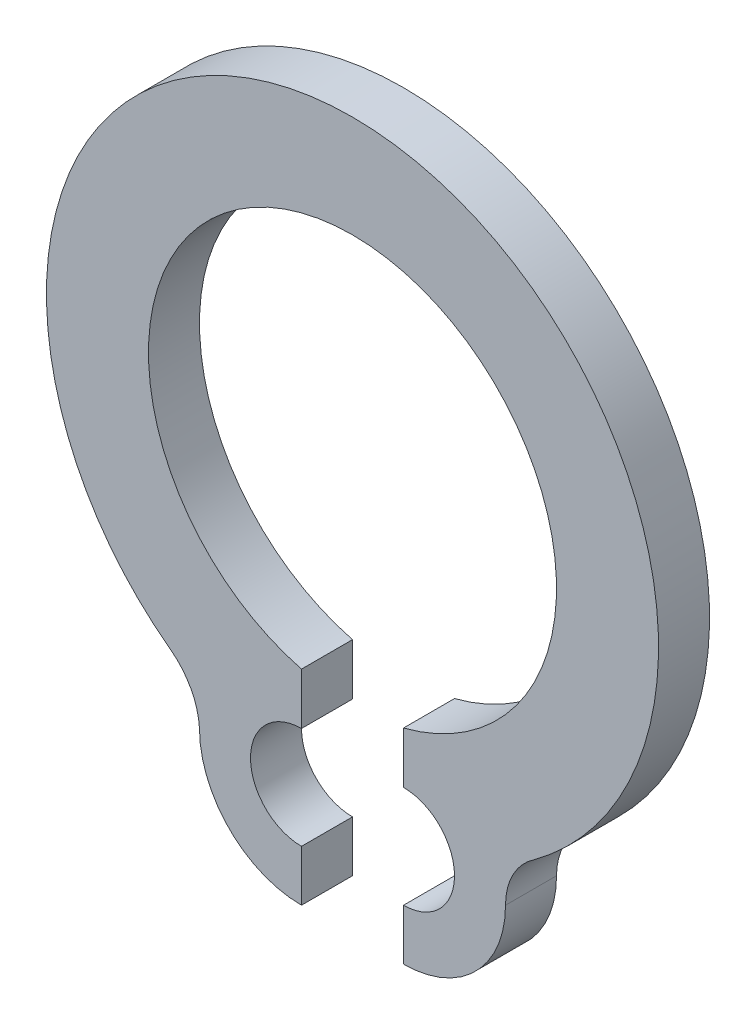
from build123d import *

# Parameters (mm, degrees)
SALIENTE_EXTRUIR1_DEPTH = 0.5


with BuildPart() as part:
    # Croquis1 → Saliente-Extruir1 (new body)
    with BuildSketch(Plane.XY):
        with BuildLine():
            Line((0.499989722, -2.441025539), (0.499989722, -1.936491673))
            ThreePointArc((0.499989722, -1.936491673), (0, 1.999997431), (-0.499989722, -1.936491673))
            Line((-0.499989722, -1.936491673), (-0.499989722, -2.441025539))
            ThreePointArc((-0.499989722, -2.441025539), (-0.999989722, -2.941025539), (-0.499989722, -3.441025539))
            Line((-0.499989722, -3.441025539), (-0.499989722, -3.941025539))
            ThreePointArc((-0.499989722, -3.941025539), (-1.207103771, -3.64812931), (-1.5, -2.941015261))
            ThreePointArc((-1.5, -2.941015261), (-1.584275622, -2.64357108), (-1.786707813, -2.409911864))
            ThreePointArc((-1.786707813, -2.409911864), (0, 3), (1.786707813, -2.409911864))
            ThreePointArc((1.786707813, -2.409911864), (1.576253442, -2.639240432), (1.5, -2.941015261))
            ThreePointArc((1.5, -2.941015261), (1.207103771, -3.64812931), (0.499989722, -3.941025539))
            Line((0.499989722, -3.941025539), (0.499989722, -3.441025539))
            ThreePointArc((0.499989722, -3.441025539), (0.999989722, -2.941025539), (0.499989722, -2.441025539))
        make_face()
    extrude(amount=SALIENTE_EXTRUIR1_DEPTH)


solid = part.part
